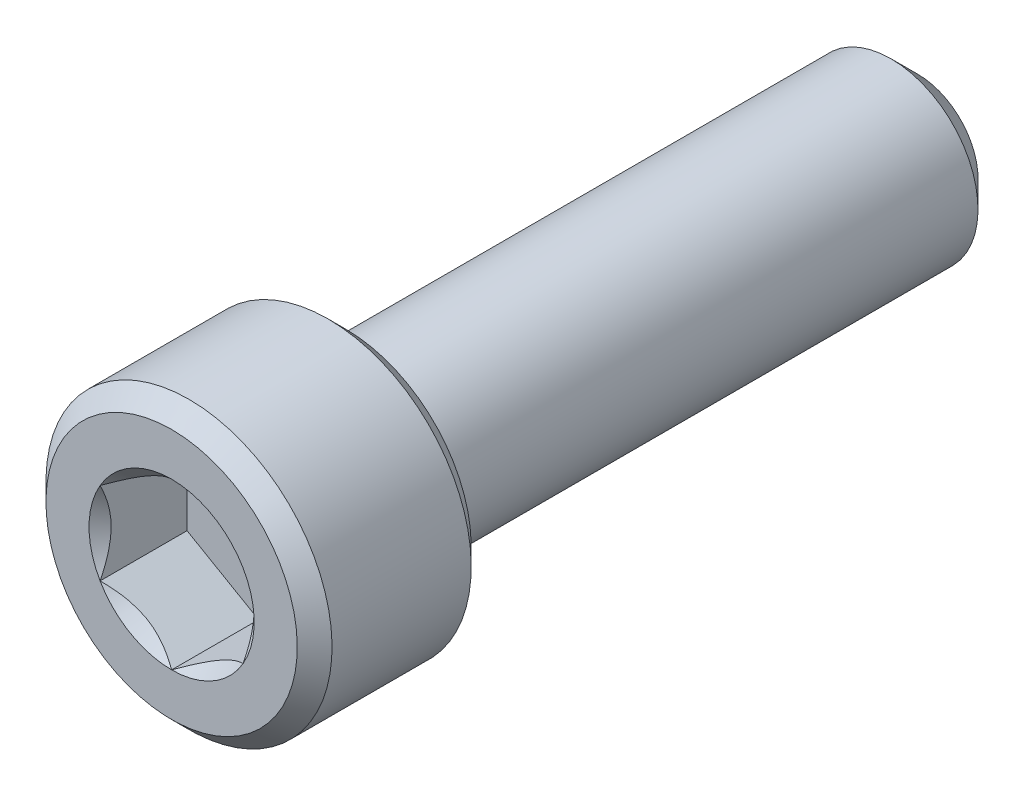
from build123d import *

# Parameters (mm, degrees)
CUT_EXTRUDE1_DEPTH = 2.413


with BuildPart() as part:
    # Sketch3 → Revolve1 (revolve)
    with BuildSketch(Plane(origin=(0, 0, 0), x_dir=(0, 0, -1), z_dir=(1, 0, 0))):
        Polygon((10.3505, 0), (-10.3505, 0), (-10.3505, 3.48615), (-9.8679, 3.96875), (-6.0071, 3.96875), (-5.5245, 3.48615), (-5.5245, 2.413), (9.609666667, 2.413), (10.3505, 1.672166667), align=None)
    revolve(axis=Axis((0, 0, -10.3505), (0, 0, 1)))

    # Sketch4 → Cut-Extrude1 (cut)
    with BuildSketch(Plane.XY.offset(10.3505)):
        Polygon((0, -2.291358881), (1.984375, -1.14567944), (1.984375, 1.14567944), (0, 2.291358881), (-1.984375, 1.14567944), (-1.984375, -1.14567944), align=None)
    extrude(amount=-CUT_EXTRUDE1_DEPTH, mode=Mode.SUBTRACT)

    # Cut-Extrude3 cone 1 section (through the dimple's axis) → Cut-Extrude3 (revolve, cut)
    with BuildSketch(Plane(origin=(0, 0, 10.3505), x_dir=(0, -1, 0), z_dir=(1, 0, 0))):
        Polygon((0, 0), (2.291358881, 0), (0, 2.291358881), align=None)
    revolve(axis=Axis((0, 0, 10.3505), (0, 0, -1)), mode=Mode.SUBTRACT)


solid = part.part
